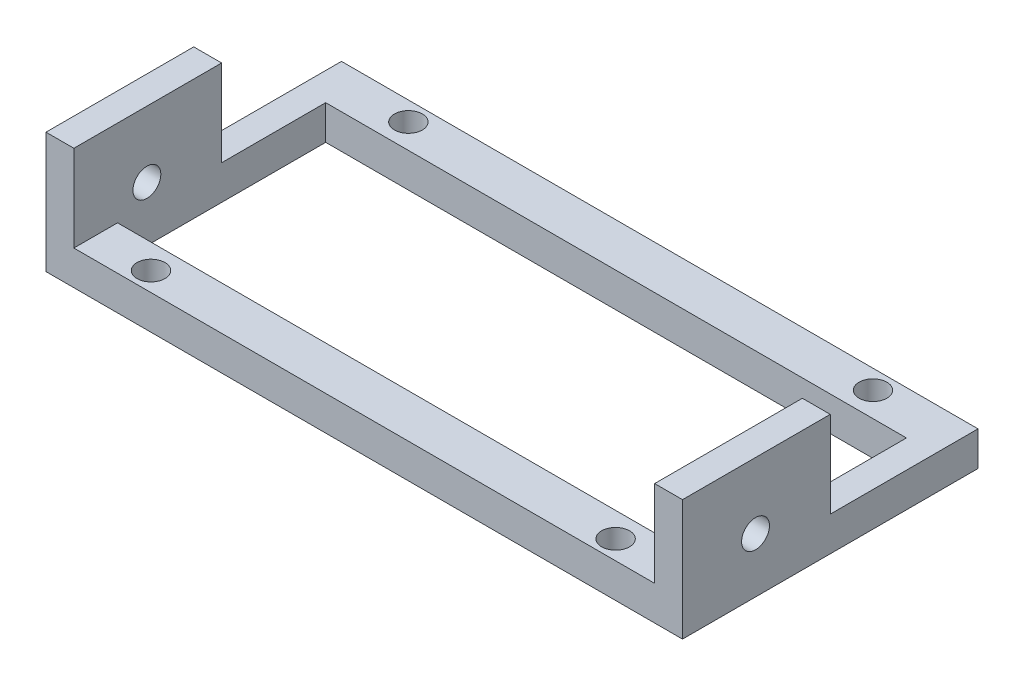
from build123d import *

# Parameters (mm, degrees)
SKETCH_1_W          = 62.5
SKETCH_1_H          = 4.7
SKETCH_1_R          = 1.5
EXTRUDE_1_DEPTH     = 3.7
SKETCH_2_W          = 31.8
SKETCH_2_H          = 3.7
EXTRUDE_2_DEPTH     = 3
SKETCH_3_W          = 3
SKETCH_3_H          = 15.9
EXTRUDE_3_DEPTH     = 13
SKETCH_4_R          = 1.5
CUT_EXTRUDE_1_DEPTH = 13


with BuildPart() as part:
    # 草图1 → 凸台-拉伸1 (new body)
    with BuildSketch(Plane(origin=(0, 0, 0), x_dir=(1, 0, 0), z_dir=(0, 1, 0))):
        Rectangle(SKETCH_1_W, SKETCH_1_H)
        with Locations((25, 0.3)):
            Circle(SKETCH_1_R, mode=Mode.SUBTRACT)
        with Locations((-25, 0.3)):
            Circle(SKETCH_1_R, mode=Mode.SUBTRACT)
    extrude_1 = extrude(amount=EXTRUDE_1_DEPTH)

    # 草图2 → 凸台-拉伸2 (add)
    with BuildSketch(Plane.ZY.offset(31.25)):
        with Locations((13.55, 1.85)):
            Rectangle(SKETCH_2_W, SKETCH_2_H)
    extrude_2 = extrude(amount=EXTRUDE_2_DEPTH)

    # 镜向1: 凸台-拉伸2 across plane
    add(extrude_2.mirror(Plane(origin=(0, 0, 0), x_dir=(0, 0, 1), z_dir=(1, 0, 0))))

    # 镜向2: 凸台-拉伸1 across plane
    add(extrude_1.mirror(Plane.XY.offset(13.55)))

    # 草图3 → 凸台-拉伸3 (add)
    with BuildSketch(Plane.XZ):
        with Locations((-32.75, 21.5)):
            Rectangle(SKETCH_3_W, SKETCH_3_H)
    extrude_3 = extrude(amount=-EXTRUDE_3_DEPTH)

    # 草图4 → 切除-拉伸1 (cut)
    with BuildSketch(Plane.ZY.offset(34.25)):
        with Locations((21.592743177, 5.9)):
            Circle(SKETCH_4_R)
    cut_extrude_1 = extrude(amount=-CUT_EXTRUDE_1_DEPTH, mode=Mode.SUBTRACT)

    # 镜向3: 凸台-拉伸3, 切除-拉伸1 across plane
    add(extrude_3.mirror(Plane(origin=(0, 0, 0), x_dir=(0, 0, 1), z_dir=(1, 0, 0))))
    add(cut_extrude_1.mirror(Plane(origin=(0, 0, 0), x_dir=(0, 0, 1), z_dir=(1, 0, 0))), mode=Mode.SUBTRACT)


solid = part.part
